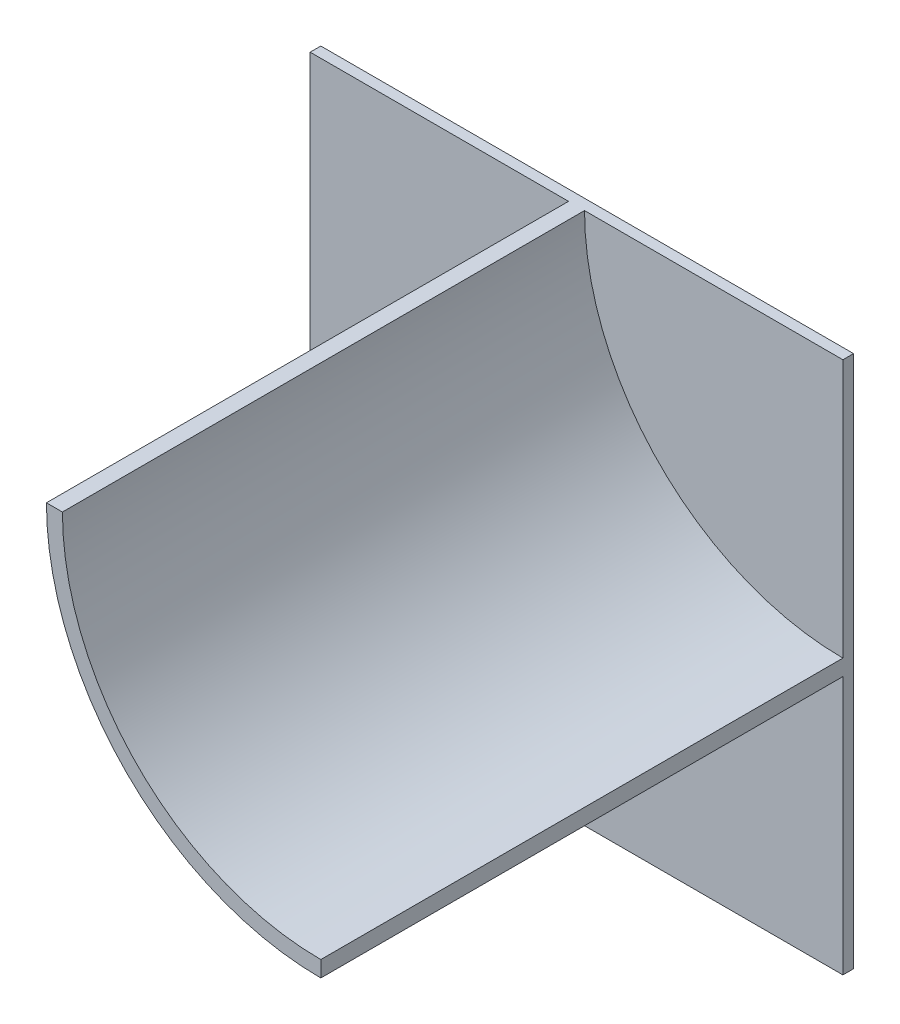
from build123d import *

# Parameters (mm, degrees)
SZKIC1_W                    = 100
SZKIC1_H                    = 100
DODANIE_WYCI_GNI_CIE1_DEPTH = 4
DODANIE_WYCI_GNI_CIE5_DEPTH = 196


with BuildPart() as part:
    # Szkic1 → Dodanie-wyciągnięcie1 (new body)
    with BuildSketch(Plane.XY):
        with Locations((-50, 50)):
            Rectangle(SZKIC1_W, SZKIC1_H)
        with Locations((50, 50)):
            Rectangle(SZKIC1_W, SZKIC1_H)
        with Locations((50, -50)):
            Rectangle(SZKIC1_W, SZKIC1_H)
        with Locations((-50, -50)):
            Rectangle(SZKIC1_W, SZKIC1_H)
    extrude(amount=DODANIE_WYCI_GNI_CIE1_DEPTH)

    # Szkic2 → Dodanie-wyciągnięcie5 (add)
    with BuildSketch(Plane.XY.offset(4)):
        with BuildLine():
            Line((0, 100), (0, 75.322074641))
            ThreePointArc((0, 75.322074641), (27.168001538, 27.168001538), (75.322074641, 0))
            Line((75.322074641, 0), (100, 0))
            Line((100, 0), (100, 3))
            ThreePointArc((100, 3), (31.410642225, 31.410642225), (3, 100))
            Line((3, 100), (0, 100))
        make_face()
        with BuildLine():
            Line((100, 0), (75.322074641, 0))
            ThreePointArc((75.322074641, 0), (87.570197105, -2.247249352), (100, -3))
            Line((100, -3), (100, 0))
        make_face()
        with BuildLine():
            ThreePointArc((-3, 100), (-2.247249352, 87.570197105), (0, 75.322074641))
            Line((0, 75.322074641), (0, 100))
            Line((0, 100), (-3, 100))
        make_face()
    extrude(amount=DODANIE_WYCI_GNI_CIE5_DEPTH)


solid = part.part
